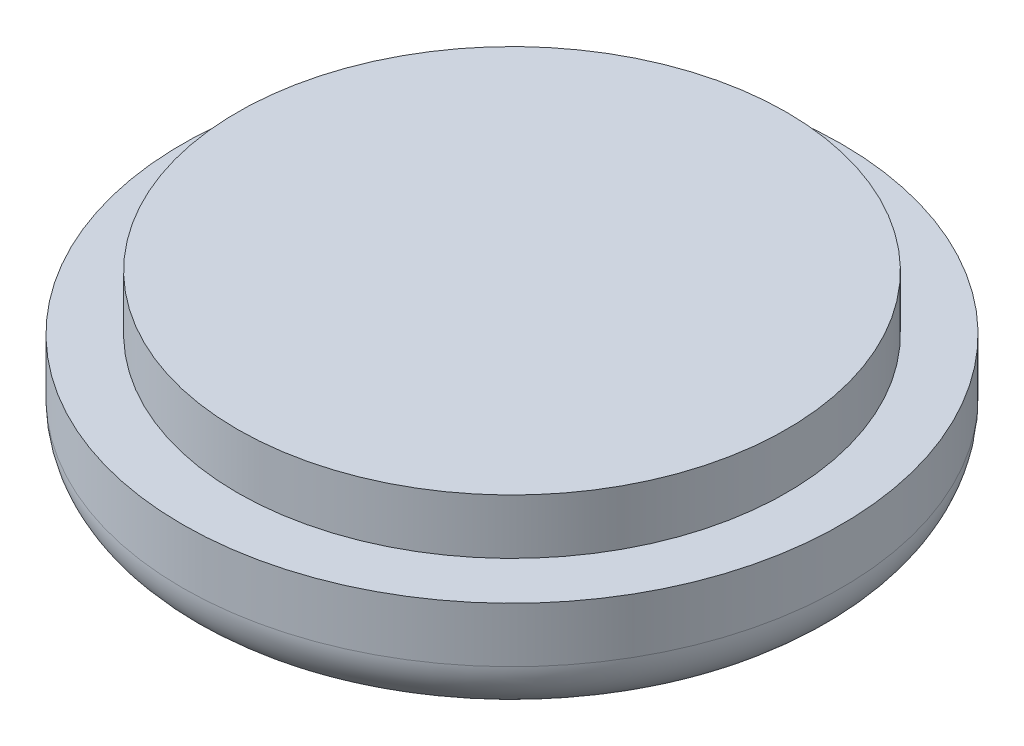
from build123d import *

# Parameters (mm, degrees)
SKETCH1_R           = 60
BOSS_EXTRUDE1_DEPTH = 20
SKETCH2_R           = 50
BOSS_EXTRUDE2_DEPTH = 10
FILLET1_R           = 10


with BuildPart() as part:
    # Sketch1 → Boss-Extrude1 (new body)
    with BuildSketch(Plane(origin=(0, 0, 0), x_dir=(1, 0, 0), z_dir=(0, 1, 0))):
        Circle(SKETCH1_R)
    extrude(amount=BOSS_EXTRUDE1_DEPTH)

    # Sketch2 → Boss-Extrude2 (add)
    with BuildSketch(Plane(origin=(0, 20, 0), x_dir=(1, 0, 0), z_dir=(0, 1, 0))):
        Circle(SKETCH2_R)
    extrude(amount=BOSS_EXTRUDE2_DEPTH)

    # Fillet1
    fillet1_edges = [part.edges().sort_by_distance(p)[0] for p in [
        (-60, 0, 0),
    ]]
    fillet(fillet1_edges, radius=FILLET1_R)


solid = part.part
